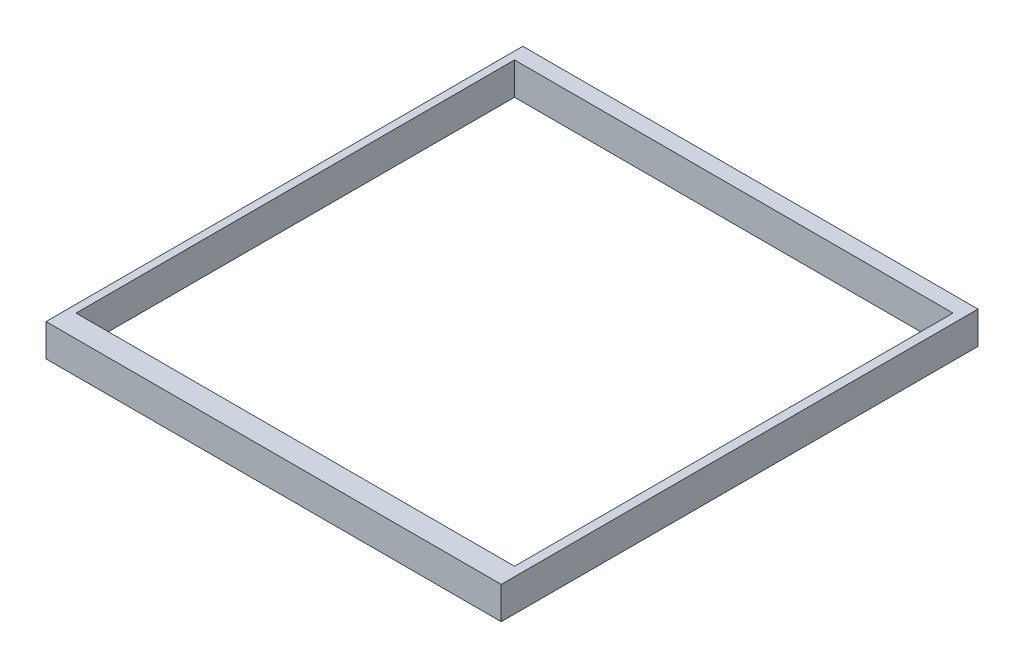
from build123d import *

# Parameters (mm, degrees)
SKETCH1_W           = 1900
SKETCH1_H           = 1990
BOSS_EXTRUDE1_DEPTH = 135
SKETCH2_W           = 1830
SKETCH2_H           = 1830
CUT_EXTRUDE2_DEPTH  = 445


with BuildPart() as part:
    # Sketch1 → Boss-Extrude1 (new body)
    with BuildSketch(Plane(origin=(214.71083156, 0, 138.123960973), x_dir=(1, 0, 0), z_dir=(0, 1, 0))):
        with Locations((961.435925314, -956.404464505)):
            Rectangle(SKETCH1_W, SKETCH1_H)
    extrude(amount=BOSS_EXTRUDE1_DEPTH)

    # Sketch2 → Cut-Extrude2 (cut)
    with BuildSketch(Plane(origin=(214.71083156, 135, 138.123960973), x_dir=(1, 0, 0), z_dir=(0, 1, 0))):
        with Locations((958.619936417, -943.058047437)):
            Rectangle(SKETCH2_W, SKETCH2_H)
    extrude(amount=-CUT_EXTRUDE2_DEPTH, mode=Mode.SUBTRACT)


solid = part.part
